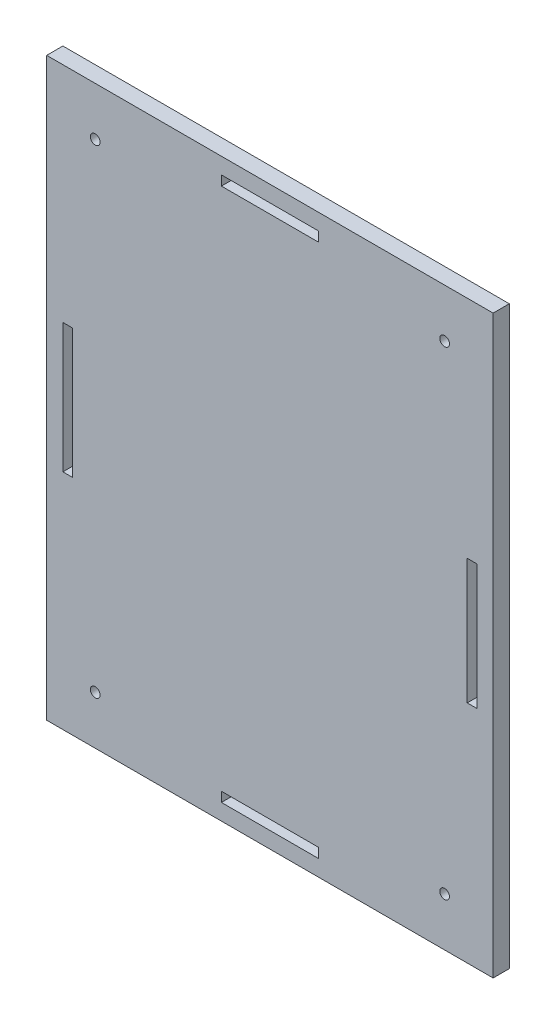
from build123d import *

# Parameters (mm, degrees)
SKETCH2_W           = 138
SKETCH2_H           = 178
BOSS_EXTRUDE1_DEPTH = 5
SKETCH3_W           = 30
SKETCH3_H           = 3
CUT_EXTRUDE1_DEPTH  = 6
SKETCH4_W           = 30
SKETCH4_H           = 3
CUT_EXTRUDE2_DEPTH  = 8
SKETCH6_W           = 3
SKETCH6_H           = 38.70967742
CUT_EXTRUDE3_DEPTH  = 8
SKETCH5_W           = 3
SKETCH5_H           = 40
CUT_EXTRUDE4_DEPTH  = 8
SKETCH8_R           = 1.5
CUT_EXTRUDE5_DEPTH  = 6


with BuildPart() as part:
    # Sketch2 → Boss-Extrude1 (new body)
    with BuildSketch(Plane.XY):
        Rectangle(SKETCH2_W, SKETCH2_H)
    extrude(amount=BOSS_EXTRUDE1_DEPTH)

    # Sketch3 → Cut-Extrude1 (cut, through all)
    with BuildSketch(Plane.XY.offset(5)):
        with Locations((0, 82.5)):
            Rectangle(SKETCH3_W, SKETCH3_H)
    extrude(amount=-CUT_EXTRUDE1_DEPTH, mode=Mode.SUBTRACT)

    # Sketch4 → Cut-Extrude2 (cut)
    with BuildSketch(Plane.XY.offset(5)):
        with Locations((0, -82.5)):
            Rectangle(SKETCH4_W, SKETCH4_H)
    extrude(amount=-CUT_EXTRUDE2_DEPTH, mode=Mode.SUBTRACT)

    # Sketch6 → Cut-Extrude3 (cut)
    with BuildSketch(Plane.XY.offset(5)):
        with Locations((62.5, 0)):
            Rectangle(SKETCH6_W, SKETCH6_H)
    extrude(amount=-CUT_EXTRUDE3_DEPTH, mode=Mode.SUBTRACT)

    # Sketch5 → Cut-Extrude4 (cut)
    with BuildSketch(Plane.XY.offset(5)):
        with Locations((-62.5, 0)):
            Rectangle(SKETCH5_W, SKETCH5_H)
    extrude(amount=-CUT_EXTRUDE4_DEPTH, mode=Mode.SUBTRACT)

    # Sketch8 → Cut-Extrude5 (cut, through all)
    with BuildSketch(Plane.XY.offset(5)):
        with Locations((54, -74)):
            Circle(SKETCH8_R)
        with Locations((54, 74)):
            Circle(SKETCH8_R)
        with Locations((-54, 74)):
            Circle(SKETCH8_R)
        with Locations((-54, -74)):
            Circle(SKETCH8_R)
    extrude(amount=-CUT_EXTRUDE5_DEPTH, mode=Mode.SUBTRACT)


solid = part.part
